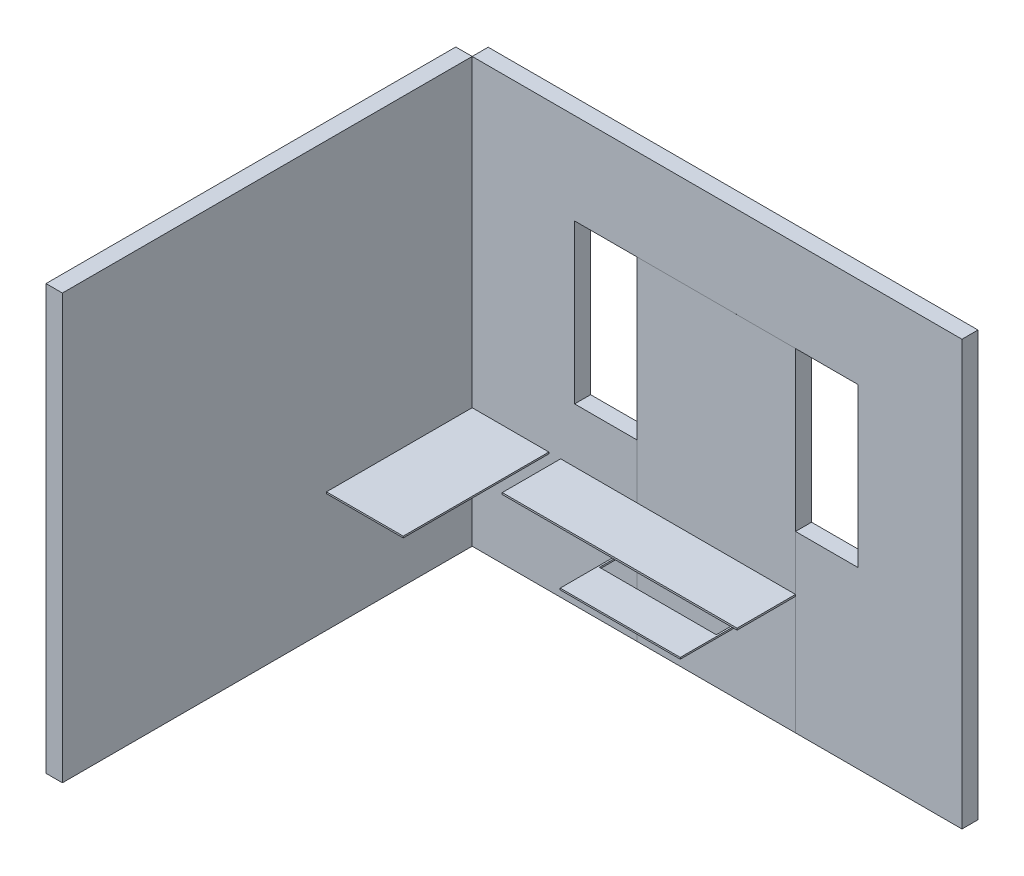
from build123d import *

# Parameters (mm, degrees)
ESBO_O6_W                = 3060
ESBO_O6_H                = 2650
RESSALTO_EXTRUS_O2_DEPTH = 100
ESBO_O7_W                = 390
ESBO_O7_H                = 990
CORTE_EXTRUS_O1_DEPTH    = 749
ESBO_O8_W                = 102.431246956
ESBO_O8_H                = 2650
RESSALTO_EXTRUS_O3_DEPTH = 2560
ESBO_O9_W                = 479.151961804
ESBO_O9_H                = 10
RESSALTO_EXTRUS_O5_DEPTH = 910
RESSALTO_EXTRUS_O7_DEPTH = 365
ESBO_O13_W               = 990
ESBO_O13_H               = 1330.610148593
RESSALTO_EXTRUS_O8_DEPTH = 0.01
ESBO_O14_W               = 750
ESBO_O14_H               = 10
RESSALTO_EXTRUS_O9_DEPTH = 600
ESBO_O16_W               = 730
ESBO_O16_H               = 365
CORTE_EXTRUS_O2_DEPTH    = 45


with BuildPart() as part:
    # Esboço6 → Ressalto-extrusão2 (new body)
    with BuildSketch(Plane.XY):
        with Locations((1530, 1325)):
            Rectangle(ESBO_O6_W, ESBO_O6_H)
    extrude(amount=RESSALTO_EXTRUS_O2_DEPTH)

    # Esboço7 → Corte-extrusão1 (cut)
    with BuildSketch(Plane.XY.offset(100)):
        with Locations((2215, 1585)):
            Rectangle(ESBO_O7_W, ESBO_O7_H)
        with Locations((835, 1585)):
            Rectangle(ESBO_O7_W, ESBO_O7_H)
    extrude(amount=-CORTE_EXTRUS_O1_DEPTH, mode=Mode.SUBTRACT)

    # Esboço12 → Ressalto-extrusão7 (add)
    with BuildSketch(Plane.XY.offset(100)):
        Polygon((552.866885131, 749.389851407), (2020, 749.389851407), (2020, 738.547480568), (552.866885131, 738.743736065), align=None)
    extrude(amount=RESSALTO_EXTRUS_O7_DEPTH)

    # Esboço13 → Ressalto-extrusão8 (add)
    with BuildSketch(Plane.XY.offset(100)):
        with Locations((1525, 1414.694925704)):
            Rectangle(ESBO_O13_W, ESBO_O13_H)
        Polygon((2020, 738.547480568), (2020, 0), (1030, 0), (1030, 738.679910911), align=None)
    extrude(amount=RESSALTO_EXTRUS_O8_DEPTH)

    # Esboço14 → Ressalto-extrusão9 (add)
    with BuildSketch(Plane.XY.offset(100.01)):
        with Locations((1525, 643.61369574)):
            Rectangle(ESBO_O14_W, ESBO_O14_H)
    extrude(amount=RESSALTO_EXTRUS_O9_DEPTH)

    # Esboço16 → Corte-extrusão2 (cut)
    with BuildSketch(Plane.XZ.offset(-638.61369574)):
        with Locations((1525, 282.51)):
            Rectangle(ESBO_O16_W, ESBO_O16_H)
    extrude(amount=-CORTE_EXTRUS_O2_DEPTH, mode=Mode.SUBTRACT)


with BuildPart() as body_2:
    # Esboço8 → Ressalto-extrusão3 (new body)
    with BuildSketch(Plane.XY.offset(100)):
        with Locations((-51.215623478, 1325)):
            Rectangle(ESBO_O8_W, ESBO_O8_H)
    extrude(amount=RESSALTO_EXTRUS_O3_DEPTH)


with BuildPart() as body_3:
    # Esboço9 → Ressalto-extrusão5 (new body)
    with BuildSketch(Plane.XY.offset(100)):
        with Locations((239.575980902, 744.389851407)):
            Rectangle(ESBO_O9_W, ESBO_O9_H)
    extrude(amount=RESSALTO_EXTRUS_O5_DEPTH)


solid = Compound([part.part, body_2.part, body_3.part])
